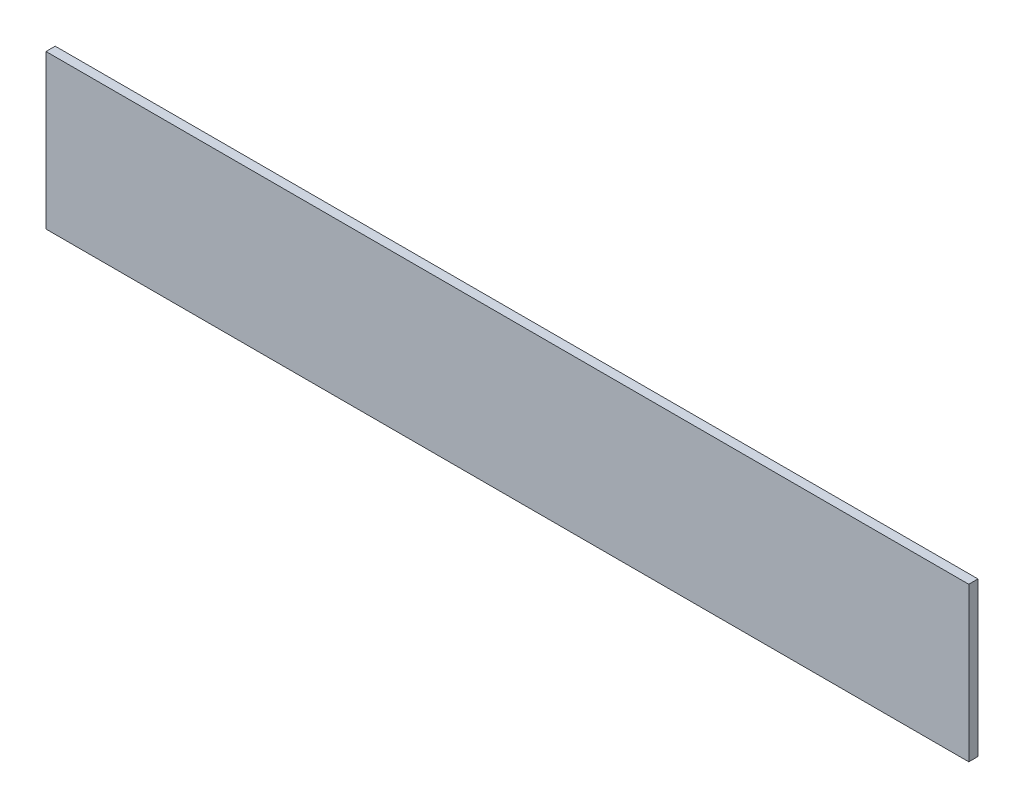
from build123d import *

# Parameters (mm, degrees)
SKETCH1_W           = 300
SKETCH1_H           = 50
BOSS_EXTRUDE1_DEPTH = 3


with BuildPart() as part:
    # Sketch1 → Boss-Extrude1 (new body)
    with BuildSketch(Plane.XY):
        Rectangle(SKETCH1_W, SKETCH1_H)
    extrude(amount=BOSS_EXTRUDE1_DEPTH)


solid = part.part
